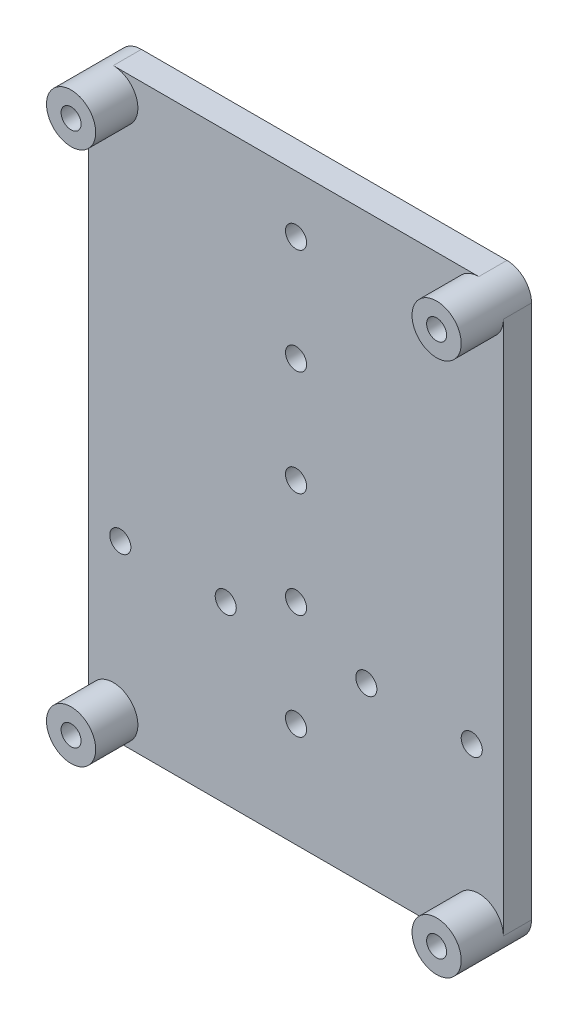
from build123d import *

# Parameters (mm, degrees)
SKETCH1_R           = 1.5
SKETCH1_R_2         = 1.4224
BOSS_EXTRUDE1_DEPTH = 4
SKETCH2_R           = 3.5
SKETCH2_R_2         = 1.4224
BOSS_EXTRUDE2_DEPTH = 6


with BuildPart() as part:
    # Sketch1 → Boss-Extrude1 (new body)
    with BuildSketch(Plane.XY.offset(189.266714263)):
        with BuildLine():
            Line((108.526557277, 109.730165261), (160.526557277, 109.730165261))
            ThreePointArc((160.526557277, 109.730165261), (163.001431011, 110.755291526), (164.026557277, 113.230165261))
            Line((164.026557277, 113.230165261), (164.026557277, 189.230165261))
            ThreePointArc((164.026557277, 189.230165261), (163.001431011, 191.705038995), (160.526557277, 192.730165261))
            Line((160.526557277, 192.730165261), (108.526557277, 192.730165261))
            ThreePointArc((108.526557277, 192.730165261), (106.051683543, 191.705038995), (105.026557277, 189.230165261))
            Line((105.026557277, 189.230165261), (105.026557277, 113.230165261))
            ThreePointArc((105.026557277, 113.230165261), (106.051683543, 110.755291526), (108.526557277, 109.730165261))
        make_face()
        with Locations((134.526557277, 124.637085275)):
            Circle(SKETCH1_R, mode=Mode.SUBTRACT)
        with Locations((109.526557277, 134.637085275)):
            Circle(SKETCH1_R, mode=Mode.SUBTRACT)
        with Locations((124.526557277, 134.637085275)):
            Circle(SKETCH1_R, mode=Mode.SUBTRACT)
        with Locations((159.526557277, 134.637085275)):
            Circle(SKETCH1_R, mode=Mode.SUBTRACT)
        with Locations((144.526557277, 134.637085275)):
            Circle(SKETCH1_R, mode=Mode.SUBTRACT)
        with Locations((134.526557277, 139.637085275)):
            Circle(SKETCH1_R, mode=Mode.SUBTRACT)
        with Locations((134.526557277, 154.637085275)):
            Circle(SKETCH1_R, mode=Mode.SUBTRACT)
        with Locations((134.526557277, 169.637085275)):
            Circle(SKETCH1_R, mode=Mode.SUBTRACT)
        with Locations((134.526557277, 184.637085275)):
            Circle(SKETCH1_R, mode=Mode.SUBTRACT)
        with Locations((108.526557277, 189.230165261)):
            Circle(SKETCH1_R_2, mode=Mode.SUBTRACT)
        with Locations((160.526557277, 189.230165261)):
            Circle(SKETCH1_R_2, mode=Mode.SUBTRACT)
        with Locations((160.526557277, 113.230165261)):
            Circle(SKETCH1_R_2, mode=Mode.SUBTRACT)
        with Locations((108.526557277, 113.230165261)):
            Circle(SKETCH1_R_2, mode=Mode.SUBTRACT)
    extrude(amount=BOSS_EXTRUDE1_DEPTH)

    # Sketch2 → Boss-Extrude2 (add)
    with BuildSketch(Plane.XY.offset(193.266714263)):
        with Locations((108.526557277, 189.230165261)):
            Circle(SKETCH2_R)
        with Locations((108.526557277, 189.230165261)):
            Circle(SKETCH2_R_2, mode=Mode.SUBTRACT)
        with Locations((160.526557277, 189.230165261)):
            Circle(SKETCH2_R)
        with Locations((160.526557277, 189.230165261)):
            Circle(SKETCH2_R_2, mode=Mode.SUBTRACT)
        with Locations((108.526557277, 113.230165261)):
            Circle(SKETCH2_R)
        with Locations((108.526557277, 113.230165261)):
            Circle(SKETCH2_R_2, mode=Mode.SUBTRACT)
        with Locations((160.526557277, 113.230165261)):
            Circle(SKETCH2_R)
        with Locations((160.526557277, 113.230165261)):
            Circle(SKETCH2_R_2, mode=Mode.SUBTRACT)
    extrude(amount=BOSS_EXTRUDE2_DEPTH)


solid = part.part
